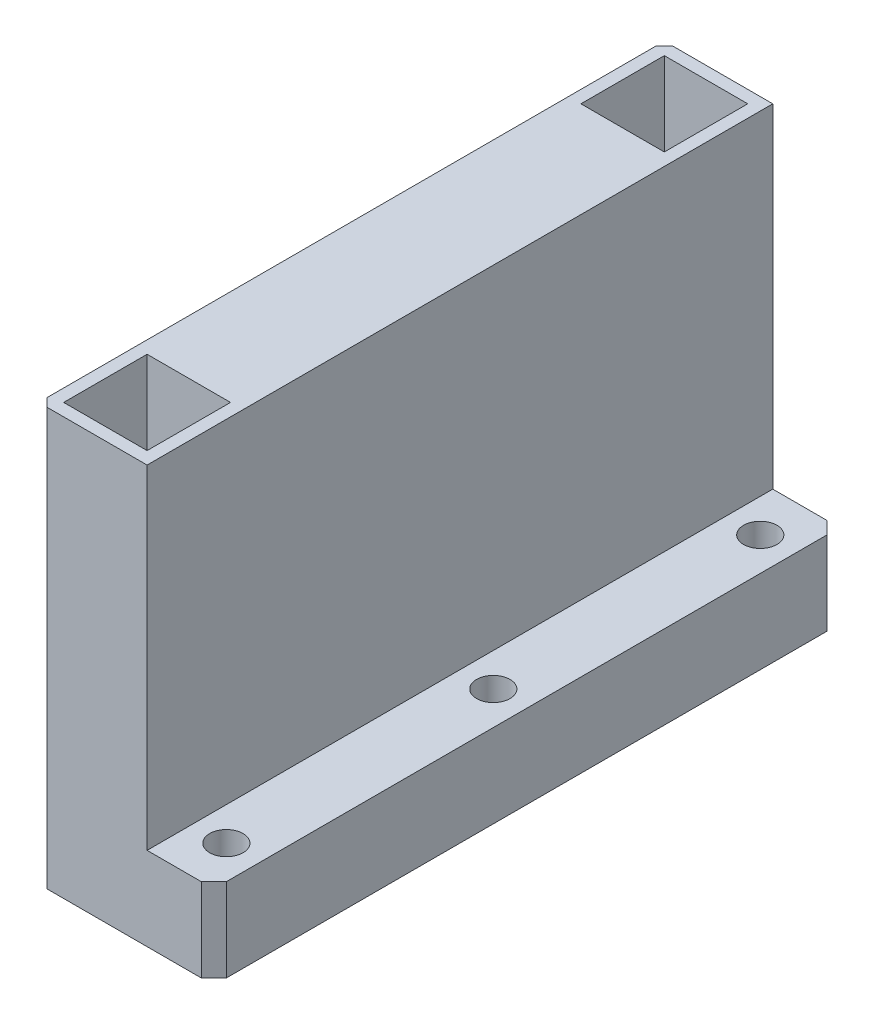
from build123d import *

# Parameters (mm, degrees)
BOSS_EXTRUDE1_DEPTH = 75
SKETCH3_W           = 10
SKETCH3_H           = 10
CUT_EXTRUDE1_DEPTH  = 10
SKETCH4_R           = 2
CUT_EXTRUDE2_DEPTH  = 11
CHAMFER1_SIZE       = 1.5
CHAMFER2_SIZE       = 1


with BuildPart() as part:
    # Sketch2 → Boss-Extrude1 (new body)
    with BuildSketch(Plane.XY):
        Polygon((13, 50), (13, 10), (21, 10), (21, 0), (0, 0), (0, 50), align=None)
    extrude(amount=BOSS_EXTRUDE1_DEPTH)

    # Sketch3 → Cut-Extrude1 (cut)
    with BuildSketch(Plane(origin=(0, 50, 0), x_dir=(1, 0, 0), z_dir=(0, 1, 0))):
        with Locations((6.5, -6.5)):
            Rectangle(SKETCH3_W, SKETCH3_H)
        with Locations((6.5, -68.5)):
            Rectangle(SKETCH3_W, SKETCH3_H)
    extrude(amount=-CUT_EXTRUDE1_DEPTH, mode=Mode.SUBTRACT)

    # Sketch4 → Cut-Extrude2 (cut, through all)
    with BuildSketch(Plane(origin=(0, 10, 0), x_dir=(1, 0, 0), z_dir=(0, 1, 0))):
        with Locations((17, -5.5)):
            Circle(SKETCH4_R)
        with Locations((17, -37.5)):
            Circle(SKETCH4_R)
        with Locations((17, -69.5)):
            Circle(SKETCH4_R)
    extrude(amount=-CUT_EXTRUDE2_DEPTH, mode=Mode.SUBTRACT)

    # Chamfer1
    chamfer1_edges = [part.edges().sort_by_distance(p)[0] for p in [
        (21, 5, 75),
        (21, 5, 0),
    ]]
    chamfer(chamfer1_edges, length=CHAMFER1_SIZE)

    # Chamfer2
    chamfer2_edges = [part.edges().sort_by_distance(p)[0] for p in [
        (0, 25, 75),
        (0, 25, 0),
    ]]
    chamfer(chamfer2_edges, length=CHAMFER2_SIZE)


solid = part.part
